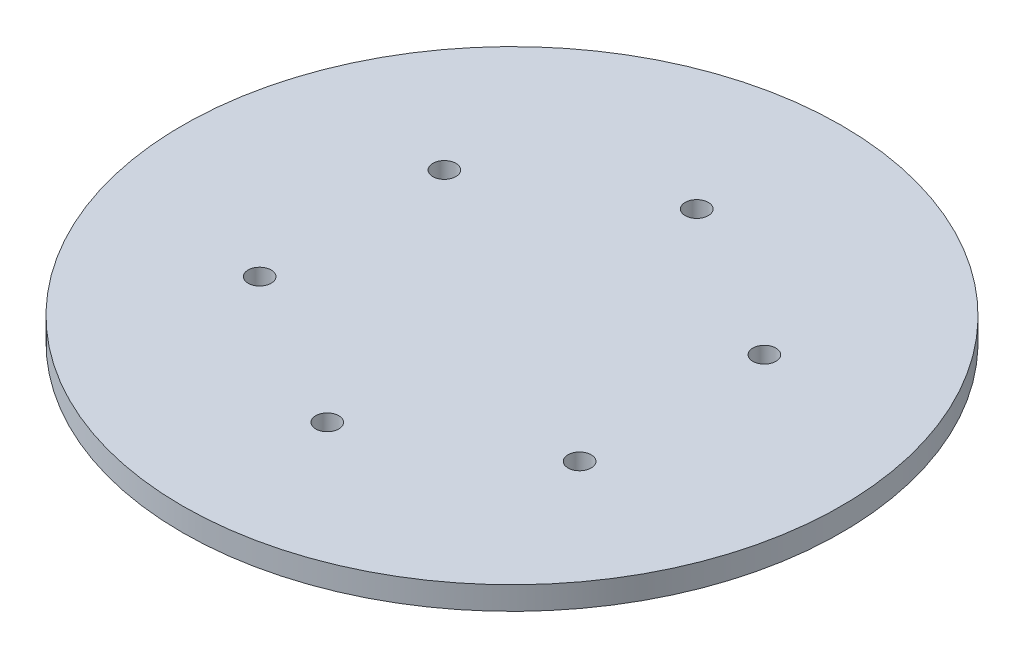
from build123d import *

# Parameters (mm, degrees)
SKETCH_1_R      = 142.710997442
SKETCH_1_R_2    = 5
EXTRUDE_1_DEPTH = 10


with BuildPart() as part:
    # 草图1 → 凸台-拉伸1 (new body)
    with BuildSketch(Plane(origin=(0, 0, 0), x_dir=(1, 0, 0), z_dir=(0, 1, 0))):
        Circle(SKETCH_1_R)
        with Locations((0, 80)):
            Circle(SKETCH_1_R_2, mode=Mode.SUBTRACT)
        with Locations((69.282032303, 40)):
            Circle(SKETCH_1_R_2, mode=Mode.SUBTRACT)
        with Locations((69.282032303, -40)):
            Circle(SKETCH_1_R_2, mode=Mode.SUBTRACT)
        with Locations((0, -80)):
            Circle(SKETCH_1_R_2, mode=Mode.SUBTRACT)
        with Locations((-69.282032303, -40)):
            Circle(SKETCH_1_R_2, mode=Mode.SUBTRACT)
        with Locations((-69.282032303, 40)):
            Circle(SKETCH_1_R_2, mode=Mode.SUBTRACT)
    extrude(amount=EXTRUDE_1_DEPTH)


solid = part.part
